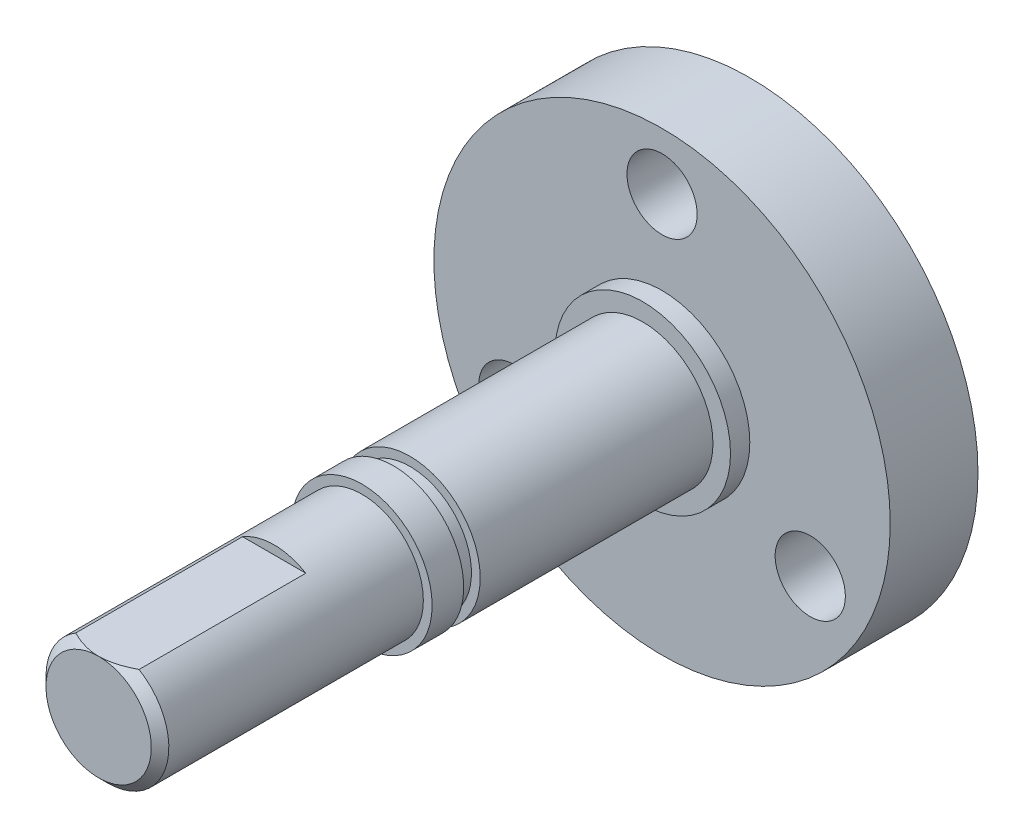
from build123d import *

# Parameters (mm, degrees)
ESQUISSE1_R                  = 13
BASE_EXTRUSION_DEPTH         = 5
ESQUISSE2_R                  = 5
BOSS_EXTRU_1_DEPTH           = 1.1
ESQUISSE3_R                  = 4
BOSS_EXTRU_2_DEPTH           = 16
ESQUISSE4_R                  = 3.5
BOSS_EXTRU_3_DEPTH           = 15
ESQUISSE5_R                  = 2
ENL_V_MAT_EXTRU_1_DEPTH      = 6
R_P_TITION_CIRCULAIRE1_COUNT = 3
ESQUISSE6_W                  = 3.116395494
ESQUISSE6_H                  = 0.94
CHANFREIN1_SIZE              = 0.5
ENL_V_MAT_EXTRU_2_DEPTH      = 10
ESQUISSE9_R                  = 6
ENL_V_MAT_EXTRU_3_DEPTH      = 1


with BuildPart() as part:
    # Esquisse1 → Base-Extrusion (new body)
    with BuildSketch(Plane.XY):
        Circle(ESQUISSE1_R)
    extrude(amount=BASE_EXTRUSION_DEPTH)

    # Esquisse2 → Boss.-Extru.1 (add)
    with BuildSketch(Plane.XY.offset(5)):
        Circle(ESQUISSE2_R)
    extrude(amount=BOSS_EXTRU_1_DEPTH)

    # Esquisse3 → Boss.-Extru.2 (add)
    with BuildSketch(Plane.XY.offset(6.1)):
        Circle(ESQUISSE3_R)
    extrude(amount=BOSS_EXTRU_2_DEPTH)

    # Esquisse4 → Boss.-Extru.3 (add)
    with BuildSketch(Plane.XY.offset(22.1)):
        Circle(ESQUISSE4_R)
    extrude(amount=BOSS_EXTRU_3_DEPTH)

    # Esquisse5 → Enlèv. mat.-Extru.1 (cut, through all)
    with BuildSketch(Plane.XY.offset(5)):
        with Locations((0, 9.75)):
            Circle(ESQUISSE5_R)
    enl_v_mat_extru_1 = extrude(amount=-ENL_V_MAT_EXTRU_1_DEPTH, mode=Mode.SUBTRACT)

    # Répétition circulaire1: Enlèv. mat.-Extru.1 ×3 about axis
    r_p_tition_circulaire1_axis = Axis((0, 0, 0), (0, 0, -1))
    for i in range(1, R_P_TITION_CIRCULAIRE1_COUNT):
        add(enl_v_mat_extru_1.rotate(r_p_tition_circulaire1_axis, i * 360 / R_P_TITION_CIRCULAIRE1_COUNT), mode=Mode.SUBTRACT)

    # Esquisse6 → Enlèvement de matière-Révolution1 (revolve, cut)
    with BuildSketch(Plane(origin=(0, 0, 0), x_dir=(1, 0, 0), z_dir=(0, 1, 0))):
        with Locations((5.058197747, -19.83)):
            Rectangle(ESQUISSE6_W, ESQUISSE6_H)
    revolve(axis=Axis((0, 0, 28.771832847), (0, 0, 1)), mode=Mode.SUBTRACT)

    # Chanfrein1
    chanfrein1_edges = [part.edges().sort_by_distance(p)[0] for p in [
        (-3.5, 0, 37.1),
    ]]
    chamfer(chanfrein1_edges, length=CHANFREIN1_SIZE)

    # Esquisse8 → Enlèv. mat.-Extru.2 (cut)
    with BuildSketch(Plane.XY.offset(37.1)):
        with BuildLine():
            Line((-1.802775638, 3), (1.802775638, 3))
            ThreePointArc((1.802775638, 3), (0, 3.5), (-1.802775638, 3))
        make_face()
    extrude(amount=-ENL_V_MAT_EXTRU_2_DEPTH, mode=Mode.SUBTRACT)

    # Esquisse9 → Enlèv. mat.-Extru.3 (cut)
    with BuildSketch(Plane(origin=(0, 0, 0), x_dir=(-1, 0, 0), z_dir=(0, 0, -1))):
        Circle(ESQUISSE9_R)
    extrude(amount=-ENL_V_MAT_EXTRU_3_DEPTH, mode=Mode.SUBTRACT)


solid = part.part
